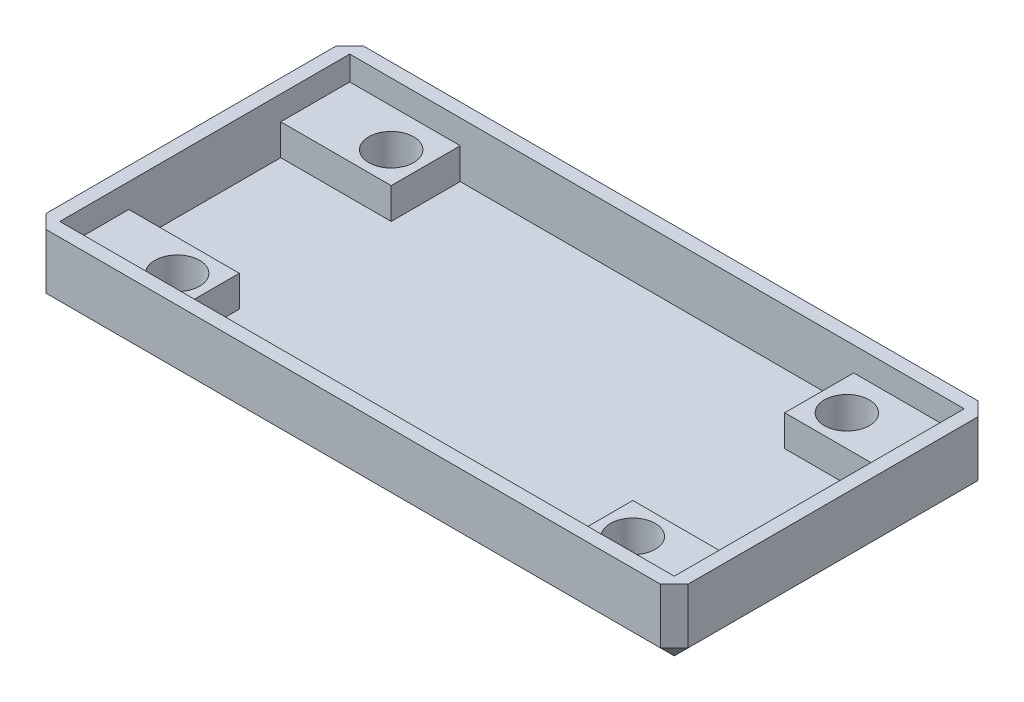
from build123d import *

# Parameters (mm, degrees)
SKETCH1_W           = 46.5
SKETCH1_H           = 23
BOSS_EXTRUDE1_DEPTH = 5
SKETCH2_W           = 44.5
SKETCH2_H           = 21
CUT_EXTRUDE1_DEPTH  = 4
SKETCH3_W           = 8
SKETCH3_H           = 5
BOSS_EXTRUDE2_DEPTH = 2.25
SKETCH4_R           = 1.625
CUT_EXTRUDE2_DEPTH  = 4.25
CHAMFER1_SIZE       = 1


with BuildPart() as part:
    # Sketch1 → Boss-Extrude1 (new body)
    with BuildSketch(Plane(origin=(0, 0, 0), x_dir=(1, 0, 0), z_dir=(0, 1, 0))):
        Rectangle(SKETCH1_W, SKETCH1_H)
    extrude(amount=BOSS_EXTRUDE1_DEPTH)

    # Sketch2 → Cut-Extrude1 (cut)
    with BuildSketch(Plane(origin=(0, 5, 0), x_dir=(1, 0, 0), z_dir=(0, 1, 0))):
        Rectangle(SKETCH2_W, SKETCH2_H)
    extrude(amount=-CUT_EXTRUDE1_DEPTH, mode=Mode.SUBTRACT)

    # Sketch3 → Boss-Extrude2 (add)
    with BuildSketch(Plane(origin=(0, 1, 0), x_dir=(1, 0, 0), z_dir=(0, 1, 0))):
        with Locations((-18.25, 8)):
            Rectangle(SKETCH3_W, SKETCH3_H)
        with Locations((18.25, 8)):
            Rectangle(SKETCH3_W, SKETCH3_H)
        with Locations((18.25, -8)):
            Rectangle(SKETCH3_W, SKETCH3_H)
        with Locations((-18.25, -8)):
            Rectangle(SKETCH3_W, SKETCH3_H)
    extrude(amount=BOSS_EXTRUDE2_DEPTH)

    # Sketch4 → Cut-Extrude2 (cut, through all)
    with BuildSketch(Plane(origin=(0, 3.25, 0), x_dir=(1, 0, 0), z_dir=(0, 1, 0))):
        with Locations((-16.5, 7.75)):
            Circle(SKETCH4_R)
        with Locations((16.5, 7.75)):
            Circle(SKETCH4_R)
        with Locations((16.5, -7.75)):
            Circle(SKETCH4_R)
        with Locations((-16.5, -7.75)):
            Circle(SKETCH4_R)
    extrude(amount=-CUT_EXTRUDE2_DEPTH, mode=Mode.SUBTRACT)

    # Chamfer1
    chamfer1_edges = [part.edges().sort_by_distance(p)[0] for p in [
        (0, 0, 11.5),
        (-23.25, 0, 0),
        (0, 0, -11.5),
        (23.25, 0, 0),
        (23.25, 2.5, 11.5),
        (-23.25, 2.5, 11.5),
        (-23.25, 2.5, -11.5),
        (23.25, 2.5, -11.5),
    ]]
    chamfer(chamfer1_edges, length=CHAMFER1_SIZE)


solid = part.part
